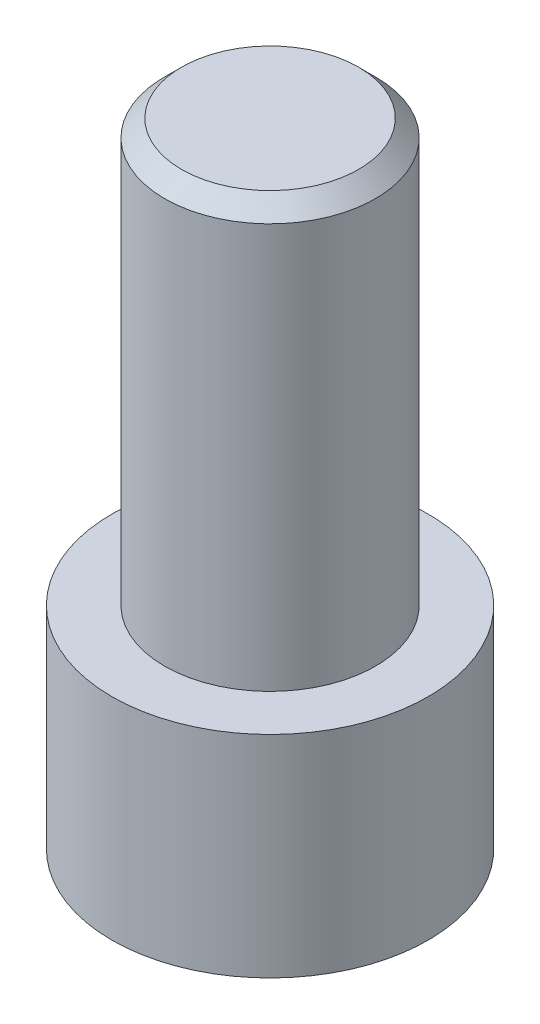
from build123d import *

# Parameters (mm, degrees)
SKETCH1_R           = 4.7625
BOSS_EXTRUDE1_DEPTH = 6.35
SKETCH1_3_R         = 3.175
BOSS_EXTRUDE2_DEPTH = 12.7
CHAMFER1_SIZE       = 0.508
CUT_EXTRUDE1_DEPTH  = 3.81


with BuildPart() as part:
    # Sketch1 → Boss-Extrude1 (new body)
    with BuildSketch(Plane(origin=(0, 0, 0), x_dir=(1, 0, 0), z_dir=(0, 1, 0))):
        Circle(SKETCH1_R)
    extrude(amount=-BOSS_EXTRUDE1_DEPTH)

    # Sketch1_3 → Boss-Extrude2 (add)
    with BuildSketch(Plane(origin=(0, 0, 0), x_dir=(1, 0, 0), z_dir=(0, 1, 0))):
        Circle(SKETCH1_3_R)
    extrude(amount=BOSS_EXTRUDE2_DEPTH)

    # Chamfer1
    chamfer1_edges = [part.edges().sort_by_distance(p)[0] for p in [
        (-3.175, 12.7, 0),
    ]]
    chamfer(chamfer1_edges, length=CHAMFER1_SIZE)

    # Sketch2 → Cut-Extrude1 (cut)
    with BuildSketch(Plane.XZ.offset(6.35)):
        Polygon((1.27, -2.199704526), (2.54, 0), (1.27, 2.199704526), (-1.27, 2.199704526), (-2.54, 0), (-1.27, -2.199704526), align=None)
    extrude(amount=-CUT_EXTRUDE1_DEPTH, mode=Mode.SUBTRACT)


solid = part.part
